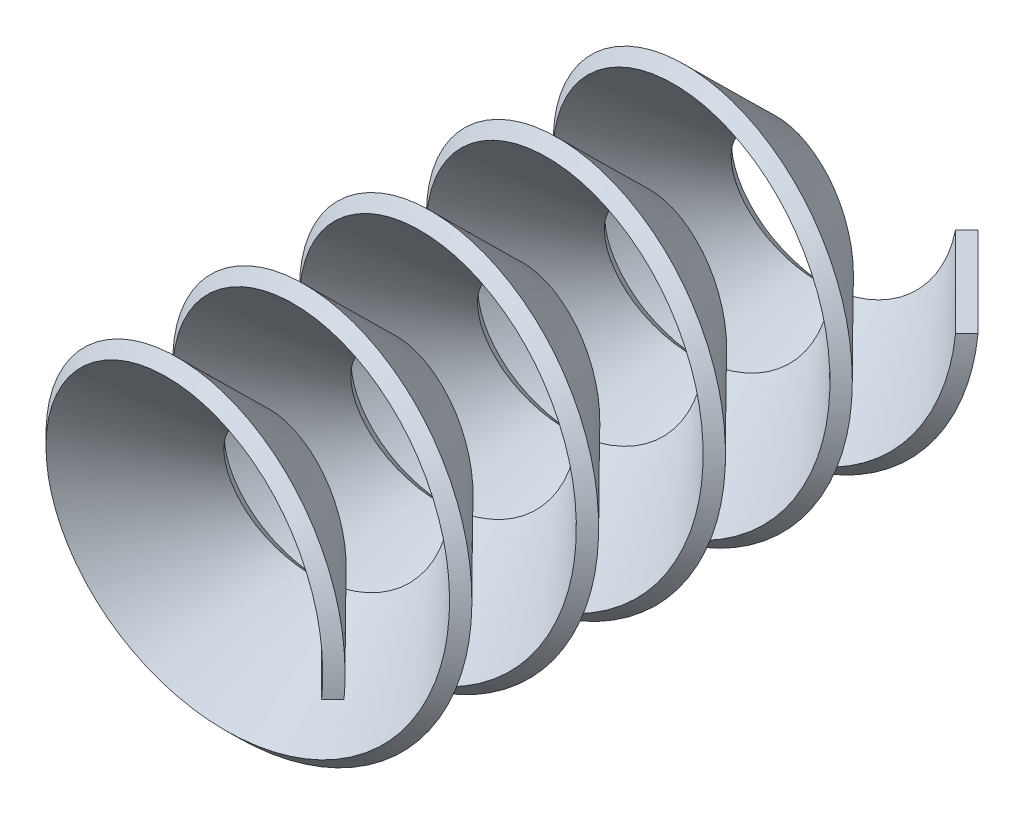
from build123d import *

# Parameters (mm, degrees)
AUSTRAGUNG1_PITCH  = 4
AUSTRAGUNG1_HEIGHT = 20
AUSTRAGUNG1_RADIUS = 2.5


with BuildPart() as part:
    # Austragung1: sweep along a helix
    with BuildLine() as austragung1_path:
        Helix(AUSTRAGUNG1_PITCH, AUSTRAGUNG1_HEIGHT, AUSTRAGUNG1_RADIUS, center=(0, 0, 0), direction=(0, 0, 1), lefthand=True)
    # Skizze2 → Austragung1 (sweep)
    with BuildSketch(Plane(origin=(0, 0, 0), x_dir=(1, 0, 0), z_dir=(0, 1, 0))):
        Polygon((2.5, -20), (5.328427125, -22.828427125), (5.681980515, -22.474873734), (2.853553391, -19.646446609), align=None)
    sweep(path=austragung1_path.line, is_frenet=True)


solid = part.part
